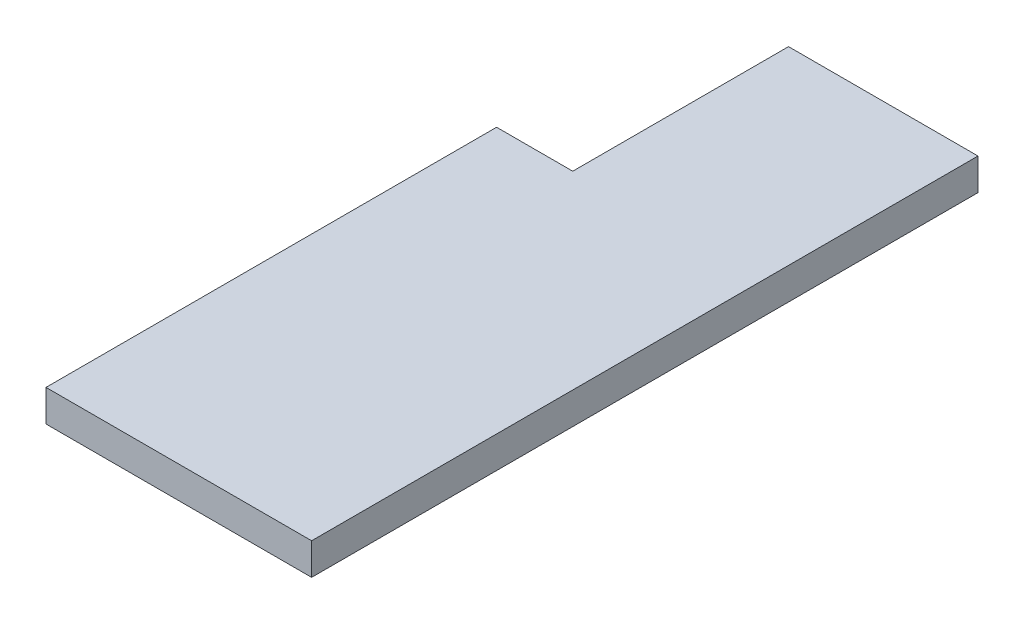
from build123d import *

# Parameters (mm, degrees)
SKETCH1_W           = 53.594
SKETCH1_H           = 82.55
BOSS_EXTRUDE1_DEPTH = 6.35
SKETCH6_W           = 53.594
SKETCH6_H           = 6.35
BOSS_EXTRUDE3_DEPTH = 7.62
SKETCH3_W           = 0.508
SKETCH3_H           = 90.17
CUT_EXTRUDE2_DEPTH  = 6.35
SKETCH8_W           = 37.338
SKETCH8_H           = 6.35
BOSS_EXTRUDE4_DEPTH = 43.18
SKETCH10_W          = 53.153164817
SKETCH10_H          = 6.35
BOSS_EXTRUDE5_DEPTH = 90.17
SKETCH11_W          = 0.575164817
SKETCH11_H          = 6.35
BOSS_EXTRUDE6_DEPTH = 43.18


with BuildPart() as part:
    # Sketch1 → Boss-Extrude1 (new body)
    with BuildSketch(Plane(origin=(0, 0, 0), x_dir=(1, 0, 0), z_dir=(0, 1, 0))):
        with Locations((-26.797, 41.275)):
            Rectangle(SKETCH1_W, SKETCH1_H)
    extrude(amount=BOSS_EXTRUDE1_DEPTH)

    # Sketch6 → Boss-Extrude3 (add)
    with BuildSketch(Plane.XY):
        with Locations((-26.797, 3.175)):
            Rectangle(SKETCH6_W, SKETCH6_H)
    extrude(amount=BOSS_EXTRUDE3_DEPTH)

    # Sketch3 → Cut-Extrude2 (cut)
    with BuildSketch(Plane(origin=(0, 6.35, 0), x_dir=(1, 0, 0), z_dir=(0, 1, 0))):
        with Locations((-0.254, 37.465)):
            Rectangle(SKETCH3_W, SKETCH3_H)
    cut_extrude2 = extrude(amount=-CUT_EXTRUDE2_DEPTH, mode=Mode.SUBTRACT)

    # Mirror1: Cut-Extrude2 across plane
    add(cut_extrude2.mirror(Plane(origin=(-26.797, 0, 0), x_dir=(0, 0, 1), z_dir=(1, 0, 0))), mode=Mode.SUBTRACT)

    # Sketch8 → Boss-Extrude4 (add)
    with BuildSketch(Plane(origin=(0, 0, -82.55), x_dir=(-1, 0, 0), z_dir=(0, 0, -1))):
        with Locations((19.177, 3.175)):
            Rectangle(SKETCH8_W, SKETCH8_H)
    extrude(amount=BOSS_EXTRUDE4_DEPTH)

    # Sketch10 → Boss-Extrude5 (add)
    with BuildSketch(Plane.XY.offset(7.62)):
        with Locations((-26.509417592, 3.175)):
            Rectangle(SKETCH10_W, SKETCH10_H)
    extrude(amount=-BOSS_EXTRUDE5_DEPTH)

    # Sketch11 → Boss-Extrude6 (add)
    with BuildSketch(Plane(origin=(0, 0, -82.55), x_dir=(-1, 0, 0), z_dir=(0, 0, -1))):
        with Locations((0.220417592, 3.175)):
            Rectangle(SKETCH11_W, SKETCH11_H)
    extrude(amount=BOSS_EXTRUDE6_DEPTH)


solid = part.part
